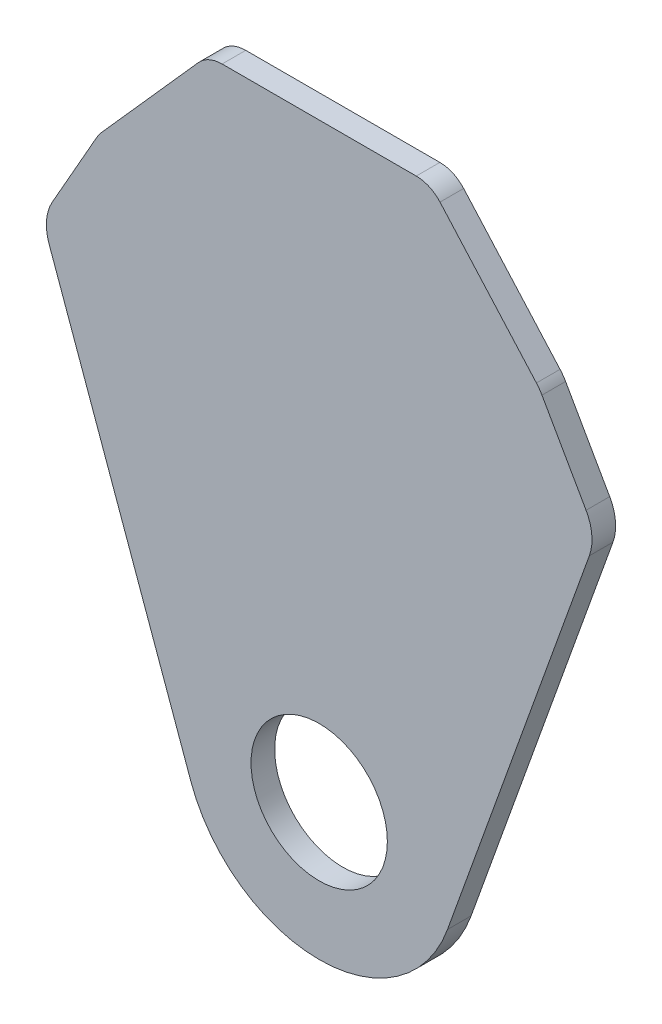
from build123d import *

# Parameters (mm, degrees)
SKETCH1_R           = 19.05
BOSS_EXTRUDE1_DEPTH = 6.604
FILLET1_R           = 12.7
FILLET2_R           = 8.89


with BuildPart() as part:
    # Sketch1 → Boss-Extrude1 (new body)
    with BuildSketch(Plane.XY):
        with BuildLine():
            Line((-31.115, 165.1), (31.115, 165.1))
            Line((31.115, 165.1), (61.595, 130.81))
            Line((61.595, 130.81), (77.47, 102.87))
            Line((77.47, 102.87), (35.853421773, -12.889613927))
            ThreePointArc((35.853421773, -12.889613927), (0, -38.1), (-35.853421773, -12.889613927))
            Line((-35.853421773, -12.889613927), (-77.47, 102.87))
            Line((-77.47, 102.87), (-61.595, 130.81))
            Line((-61.595, 130.81), (-31.115, 165.1))
        make_face()
        Circle(SKETCH1_R, mode=Mode.SUBTRACT)
    extrude(amount=BOSS_EXTRUDE1_DEPTH)

    # Fillet1
    fillet1_edges = [part.edges().sort_by_distance(p)[0] for p in [
        (61.595, 130.81, 3.302),
        (77.47, 102.87, 3.302),
        (-77.47, 102.87, 3.302),
        (-61.595, 130.81, 3.302),
    ]]
    fillet(fillet1_edges, radius=FILLET1_R)

    # Fillet2
    fillet2_edges = [part.edges().sort_by_distance(p)[0] for p in [
        (-31.115, 165.1, 3.302),
        (31.115, 165.1, 3.302),
    ]]
    fillet(fillet2_edges, radius=FILLET2_R)


solid = part.part
